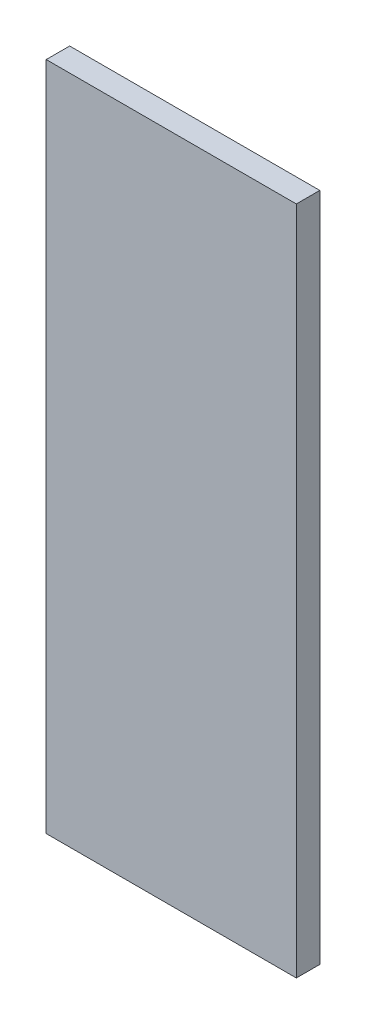
from build123d import *

# Parameters (mm, degrees)
SKETCH1_W           = 203.2
SKETCH1_H           = 19.05
BOSS_EXTRUDE1_DEPTH = 544.576


with BuildPart() as part:
    # Sketch1 → Boss-Extrude1 (new body)
    with BuildSketch(Plane(origin=(0, 0, 0), x_dir=(1, 0, 0), z_dir=(0, 1, 0))):
        with Locations((101.6, 9.525)):
            Rectangle(SKETCH1_W, SKETCH1_H)
    extrude(amount=BOSS_EXTRUDE1_DEPTH)


solid = part.part
